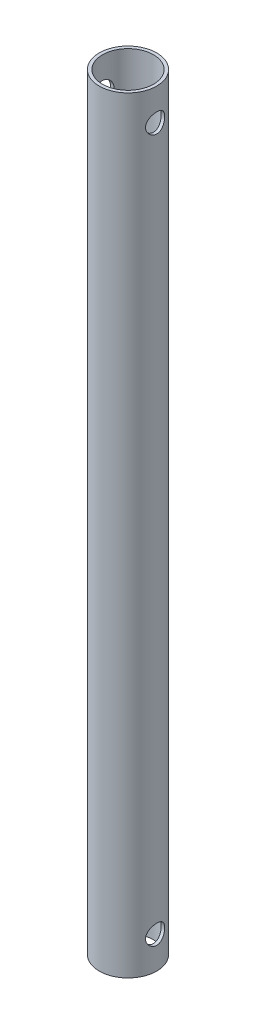
from build123d import *

# Parameters (mm, degrees)
CROQUIS1_R                 = 4.5
CROQUIS1_R_2               = 4
SALIENTE_EXTRUIR1_DEPTH    = 120
CROQUIS2_R                 = 1.5
CORTAR_EXTRUIR1_DEPTH      = 5.5
CORTAR_EXTRUIR1_DEPTH_BACK = 5.5


with BuildPart() as part:
    # Croquis1 → Saliente-Extruir1 (new body)
    with BuildSketch(Plane(origin=(0, 0, 0), x_dir=(1, 0, 0), z_dir=(0, 1, 0))):
        Circle(CROQUIS1_R)
        Circle(CROQUIS1_R_2, mode=Mode.SUBTRACT)
    extrude(amount=SALIENTE_EXTRUIR1_DEPTH)

    # Croquis2 → Cortar-Extruir1 (cut, two sides)
    with BuildSketch(Plane(origin=(0, 0, 0), x_dir=(0, 0, -1), z_dir=(1, 0, 0))) as cortar_extruir1_sk:
        with Locations((0, 115)):
            Circle(CROQUIS2_R)
        with Locations((0, 5)):
            Circle(CROQUIS2_R)
    extrude(amount=CORTAR_EXTRUIR1_DEPTH, mode=Mode.SUBTRACT)
    extrude(cortar_extruir1_sk.sketch, amount=-CORTAR_EXTRUIR1_DEPTH_BACK, mode=Mode.SUBTRACT)


solid = part.part
